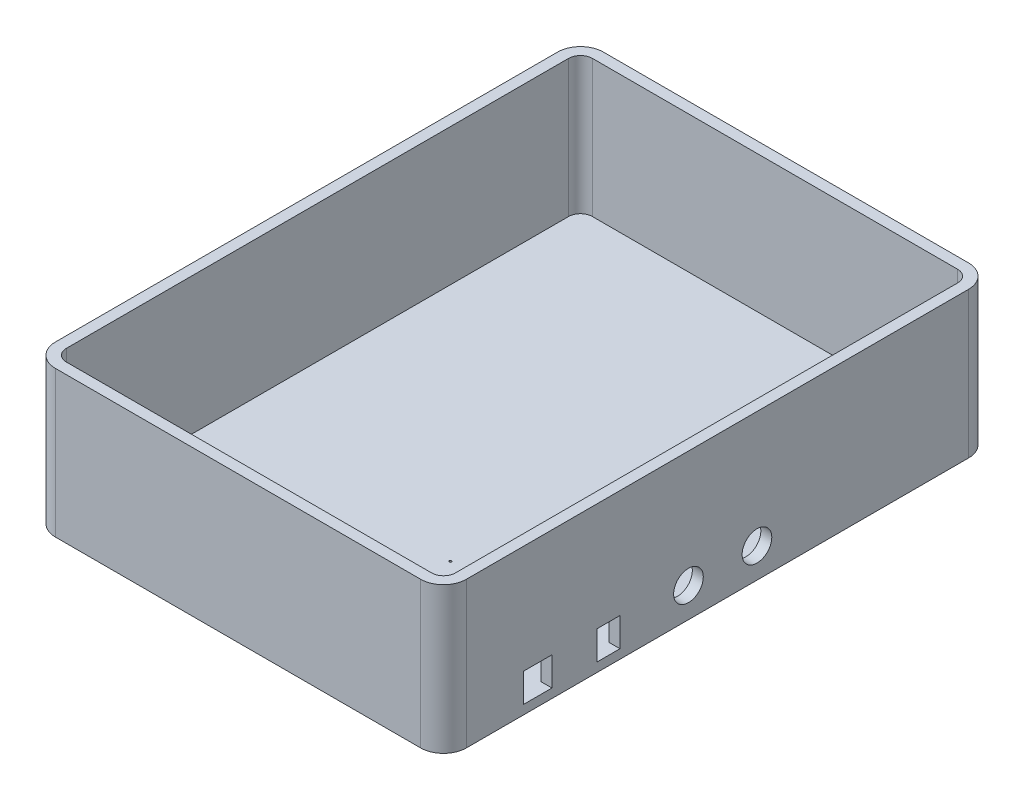
from build123d import *

# Parameters (mm, degrees)
SKETCH1_W               = 180
SKETCH1_H               = 240
BOSS_EXTRUDE1_DEPTH     = 4
FILLET1_R               = 10
BOSS_EXTRUDE2_DEPTH     = 60
SKETCH3_R               = 0.5
CUT_EXTRUDE1_DEPTH      = 61
CUT_EXTRUDE1_DEPTH_BACK = 5
SKETCH4_W               = 15
SKETCH4_H               = 12.5
SKETCH4_W_2             = 20
SKETCH4_H_2             = 10
CUT_EXTRUDE2_DEPTH      = 12.6
SKETCH5_R               = 6.5
CUT_EXTRUDE3_DEPTH      = 12.6


with BuildPart() as part:
    # Sketch1 → Boss-Extrude1 (new body)
    with BuildSketch(Plane(origin=(0, 0, 0), x_dir=(1, 0, 0), z_dir=(0, 1, 0))):
        with Locations((90, 120)):
            Rectangle(SKETCH1_W, SKETCH1_H)
    extrude(amount=BOSS_EXTRUDE1_DEPTH)

    # Fillet1
    fillet1_edges = [part.edges().sort_by_distance(p)[0] for p in [
        (0, 2, -240),
        (180, 2, -240),
        (180, 2, 0),
        (0, 2, 0),
    ]]
    fillet(fillet1_edges, radius=FILLET1_R)

    # Sketch2 → Boss-Extrude2 (add)
    with BuildSketch(Plane(origin=(0, 4, 0), x_dir=(1, 0, 0), z_dir=(0, 1, 0))):
        with BuildLine():
            Line((170, 240), (10, 240))
            ThreePointArc((10, 240), (2.928932188, 237.071067812), (0, 230))
            Line((0, 230), (0, 10))
            ThreePointArc((0, 10), (2.928932188, 2.928932188), (10, 0))
            Line((10, 0), (170, 0))
            ThreePointArc((170, 0), (177.071067812, 2.928932188), (180, 10))
            Line((180, 10), (180, 230))
            ThreePointArc((180, 230), (177.071067812, 237.071067812), (170, 240))
        make_face()
        with BuildLine():
            Line((170, 235.2), (10, 235.2))
            ThreePointArc((10, 235.2), (6.323044738, 233.676955262), (4.8, 230))
            Line((4.8, 230), (4.8, 10))
            ThreePointArc((4.8, 10), (6.323044738, 6.323044738), (10, 4.8))
            Line((10, 4.8), (170, 4.8))
            ThreePointArc((170, 4.8), (173.676955262, 6.323044738), (175.2, 10))
            Line((175.2, 10), (175.2, 230))
            ThreePointArc((175.2, 230), (173.676955262, 233.676955262), (170, 235.2))
        make_face(mode=Mode.SUBTRACT)
    extrude(amount=BOSS_EXTRUDE2_DEPTH)

    # Sketch3 → Cut-Extrude1 (cut, two sides)
    with BuildSketch(Plane(origin=(0, 4, 0), x_dir=(1, 0, 0), z_dir=(0, 1, 0))) as cut_extrude1_sk:
        with Locations((159.96, 29.8)):
            Circle(SKETCH3_R)
        with Locations((109.7, 45.3)):
            Circle(SKETCH3_R)
        with Locations((109.7, 73.3)):
            Circle(SKETCH3_R)
    extrude(amount=CUT_EXTRUDE1_DEPTH, mode=Mode.SUBTRACT)
    extrude(cut_extrude1_sk.sketch, amount=-CUT_EXTRUDE1_DEPTH_BACK, mode=Mode.SUBTRACT)

    # Sketch4 → Cut-Extrude2 (cut)
    with BuildSketch(Plane(origin=(0, 4, 0), x_dir=(1, 0, 0), z_dir=(0, 1, 0))):
        with Locations((175.2, 41.25)):
            Rectangle(SKETCH4_W, SKETCH4_H)
        with Locations((175.2, 72.29)):
            Rectangle(SKETCH4_W_2, SKETCH4_H_2)
    extrude(amount=CUT_EXTRUDE2_DEPTH, mode=Mode.SUBTRACT)

    # Sketch5 → Cut-Extrude3 (cut)
    with BuildSketch(Plane(origin=(180, 0, 0), x_dir=(0, 0, -1), z_dir=(1, 0, 0))):
        with Locations((107.29, 13)):
            Circle(SKETCH5_R)
        with Locations((137.29, 13)):
            Circle(SKETCH5_R)
    extrude(amount=-CUT_EXTRUDE3_DEPTH, mode=Mode.SUBTRACT)


solid = part.part
